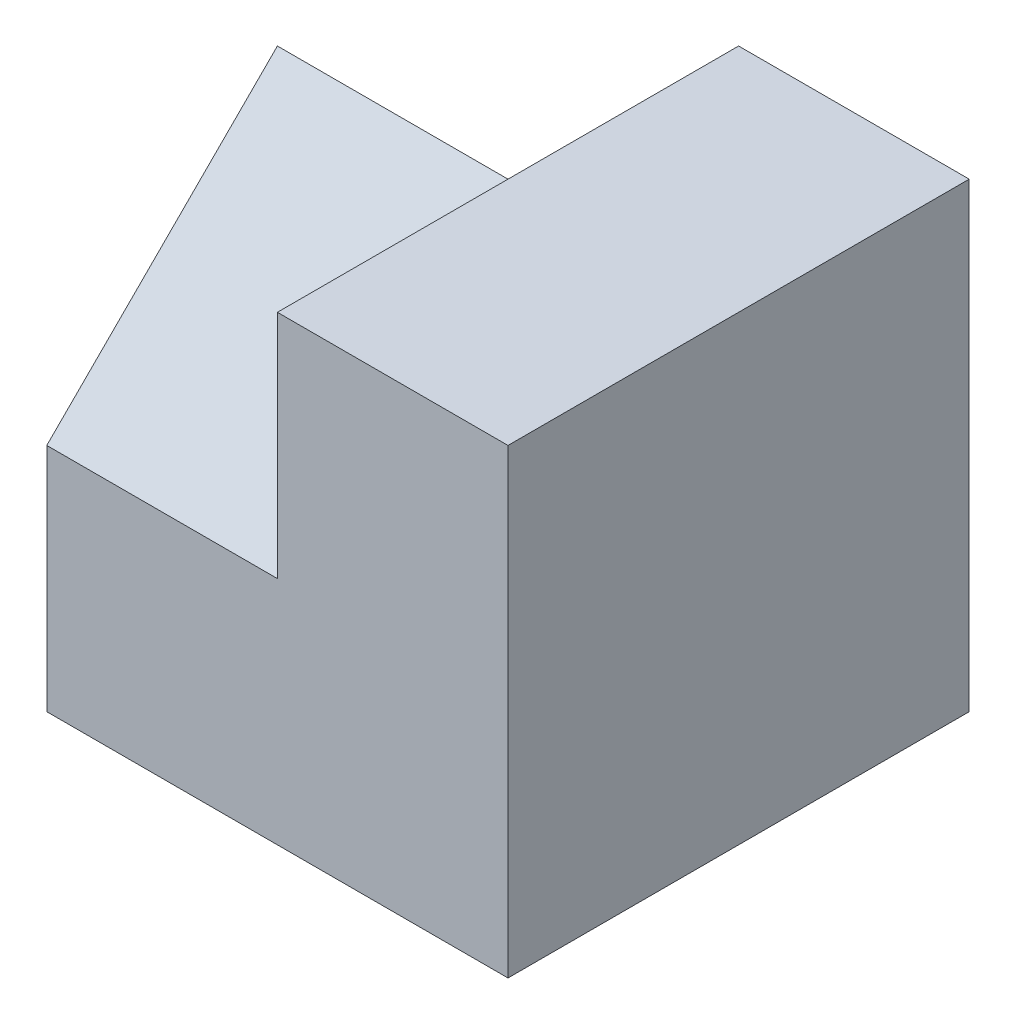
from build123d import *

# Parameters (mm, degrees)
SKETCH1_W           = 4
SKETCH1_H           = 4
BOSS_EXTRUDE1_DEPTH = 4
CUT_EXTRUDE1_DEPTH  = 2


with BuildPart() as part:
    # Sketch1 → Boss-Extrude1 (new body)
    with BuildSketch(Plane(origin=(0, 0, 0), x_dir=(1, 0, 0), z_dir=(0, 1, 0))):
        Rectangle(SKETCH1_W, SKETCH1_H)
    extrude(amount=BOSS_EXTRUDE1_DEPTH)

    # Sketch2 → Cut-Extrude1 (cut)
    with BuildSketch(Plane.ZY.offset(2)):
        Polygon((0, 4), (2, 2), (2, 4), align=None)
        with BuildLine():
            ThreePointArc((-2, 2), (-0.585786438, 2.585786438), (0, 4))
            Line((0, 4), (-2, 4))
            Line((-2, 4), (-2, 2))
        make_face()
    extrude(amount=-CUT_EXTRUDE1_DEPTH, mode=Mode.SUBTRACT)


solid = part.part
